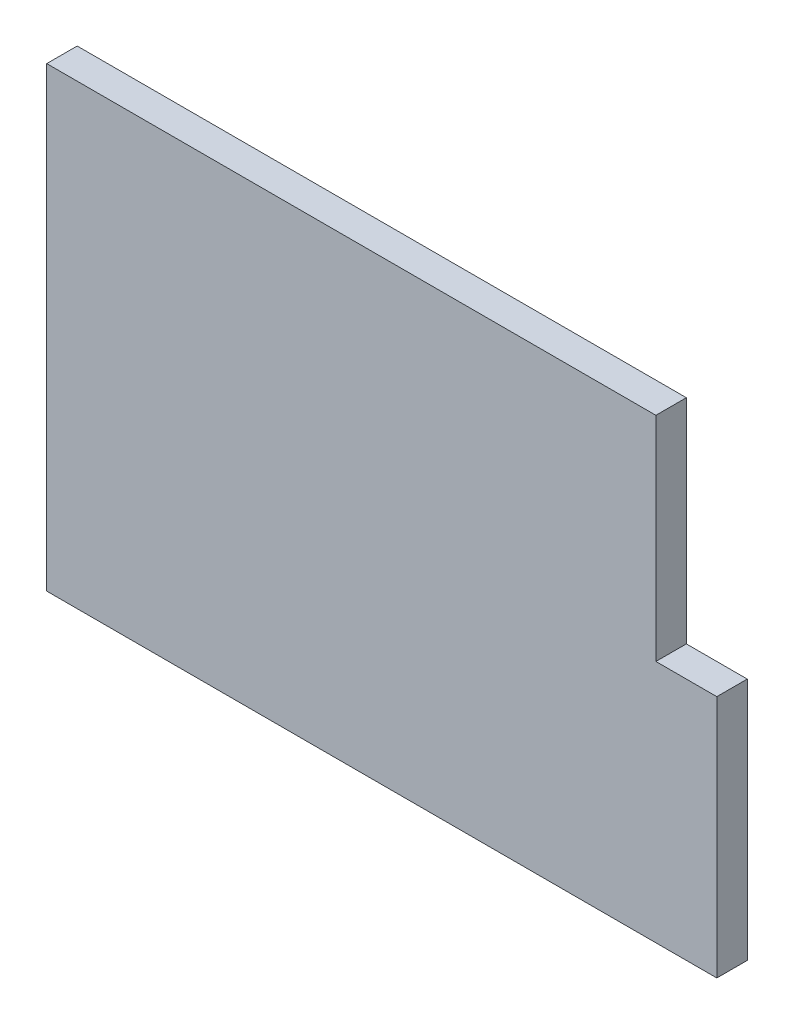
from build123d import *

# Parameters (mm, degrees)
BOSS_EXTRUDE1_DEPTH = 1


with BuildPart() as part:
    # Sketch1 → Boss-Extrude1 (new body)
    with BuildSketch(Plane.XY):
        Polygon((-10, -7.5), (10, -7.5), (12, -7.5), (12, 0.5), (10, 0.5), (10, 7.5), (-10, 7.5), align=None)
    extrude(amount=BOSS_EXTRUDE1_DEPTH)


solid = part.part
